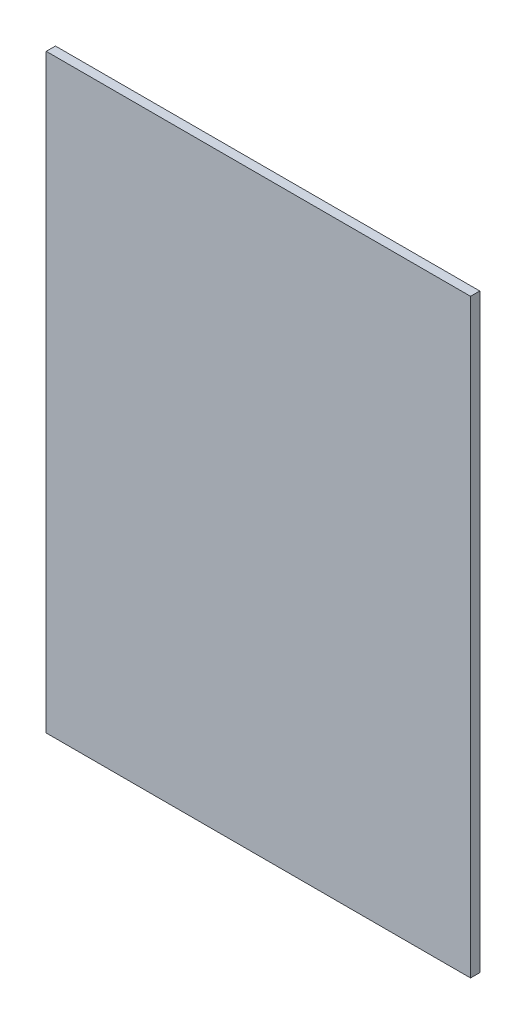
from build123d import *

# Parameters (mm, degrees)
SKETCH1_W           = 292.1
SKETCH1_H           = 406.4
BOSS_EXTRUDE1_DEPTH = 6.35


with BuildPart() as part:
    # Sketch1 → Boss-Extrude1 (new body)
    with BuildSketch(Plane.XY):
        with Locations((146.05, 203.2)):
            Rectangle(SKETCH1_W, SKETCH1_H)
    extrude(amount=BOSS_EXTRUDE1_DEPTH)


solid = part.part
